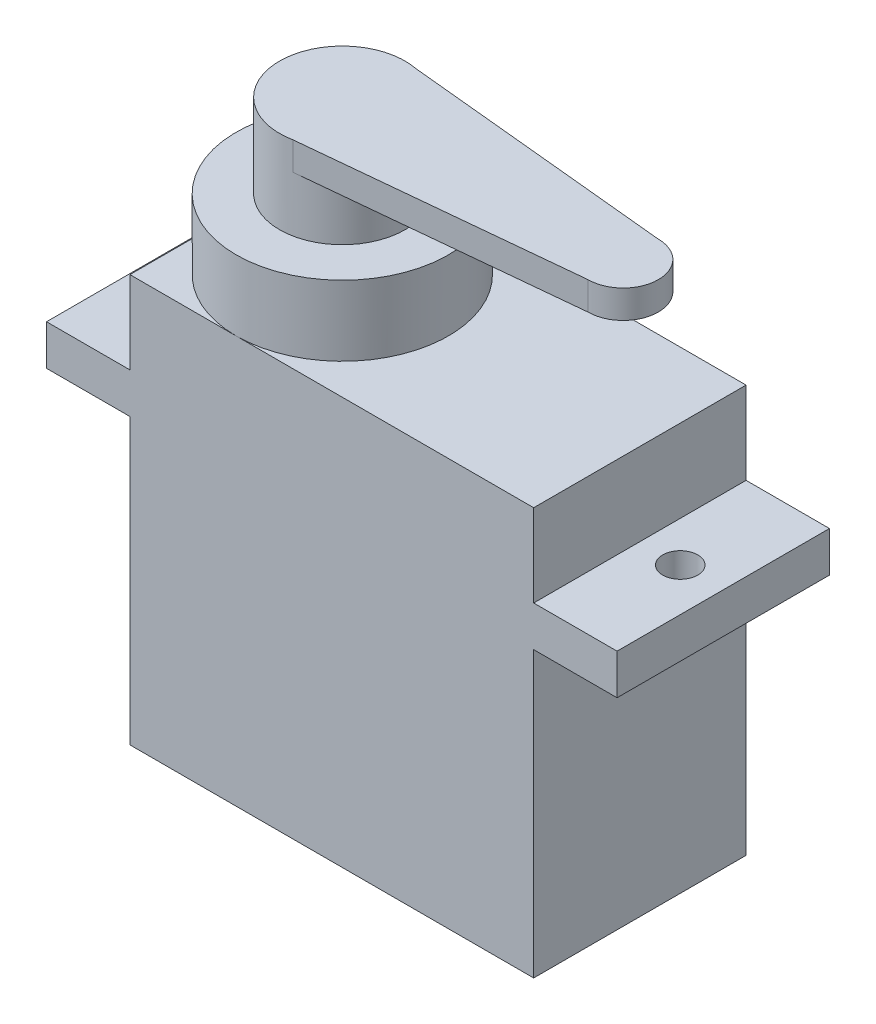
from build123d import *

# Parameters (mm, degrees)
SKETCH1_W           = 23
SKETCH1_H           = 12.1
BOSS_EXTRUDE1_DEPTH = 23.2
SKETCH2_W           = 12.1
SKETCH2_H           = 2.3
BOSS_EXTRUDE2_DEPTH = 4.75
SKETCH3_R           = 1
CUT_EXTRUDE1_DEPTH  = 2.3
SKETCH4_R           = 6.05
BOSS_EXTRUDE3_DEPTH = 4
SKETCH5_R           = 3.575
BOSS_EXTRUDE4_DEPTH = 4.75
BOSS_EXTRUDE5_DEPTH = 1.6


with BuildPart() as part:
    # Sketch1 → Boss-Extrude1 (new body)
    with BuildSketch(Plane(origin=(0, 0, 0), x_dir=(1, 0, 0), z_dir=(0, 1, 0))):
        Rectangle(SKETCH1_W, SKETCH1_H)
    extrude(amount=BOSS_EXTRUDE1_DEPTH)

    # Sketch2 → Boss-Extrude2 (add)
    with BuildSketch(Plane(origin=(11.5, 0, 0), x_dir=(0, 0, -1), z_dir=(1, 0, 0))):
        with Locations((0, 17.35)):
            Rectangle(SKETCH2_W, SKETCH2_H)
    boss_extrude2 = extrude(amount=BOSS_EXTRUDE2_DEPTH)

    # Sketch3 → Cut-Extrude1 (cut)
    with BuildSketch(Plane(origin=(0, 18.5, 0), x_dir=(1, 0, 0), z_dir=(0, 1, 0))):
        with Locations((13.8, 0)):
            Circle(SKETCH3_R)
    cut_extrude1 = extrude(amount=-CUT_EXTRUDE1_DEPTH, mode=Mode.SUBTRACT)

    # Mirror1: Boss-Extrude2, Cut-Extrude1 across plane
    add(boss_extrude2.mirror(Plane(origin=(0, 0, 0), x_dir=(0, 0, 1), z_dir=(1, 0, 0))))
    add(cut_extrude1.mirror(Plane(origin=(0, 0, 0), x_dir=(0, 0, 1), z_dir=(1, 0, 0))), mode=Mode.SUBTRACT)

    # Sketch4 → Boss-Extrude3 (add)
    with BuildSketch(Plane(origin=(0, 23.2, 0), x_dir=(1, 0, 0), z_dir=(0, 1, 0))):
        with Locations((-5.45, 0)):
            Circle(SKETCH4_R)
    extrude(amount=BOSS_EXTRUDE3_DEPTH)

    # Sketch5 → Boss-Extrude4 (add)
    with BuildSketch(Plane(origin=(0, 27.2, 0), x_dir=(1, 0, 0), z_dir=(0, 1, 0))):
        with Locations((-5.45, 0)):
            Circle(SKETCH5_R)
    extrude(amount=BOSS_EXTRUDE4_DEPTH)

    # Sketch7 → Boss-Extrude5 (add)
    with BuildSketch(Plane(origin=(0, 31.95, 0), x_dir=(1, 0, 0), z_dir=(0, 1, 0))):
        with BuildLine():
            Line((10.55, 2), (-4.752926477, 3.506381825))
            ThreePointArc((-4.752926477, 3.506381825), (-2.68660871, 2.26810352), (-1.875, 0))
            ThreePointArc((-1.875, 0), (-2.68660871, -2.26810352), (-4.752926477, -3.506381825))
            Line((-4.752926477, -3.506381825), (10.55, -2))
            ThreePointArc((10.55, -2), (12.55, 0), (10.55, 2))
        make_face()
    extrude(amount=-BOSS_EXTRUDE5_DEPTH)


solid = part.part
